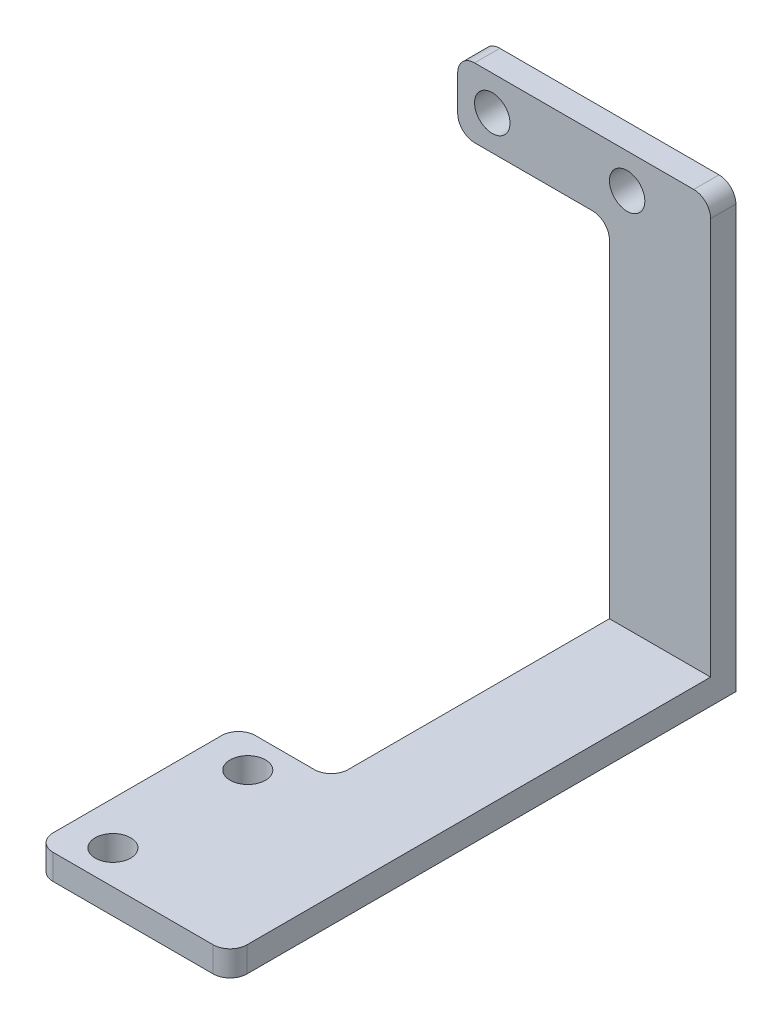
from build123d import *

# Parameters (mm, degrees)
SKETCH1_R           = 2.1
BOSS_EXTRUDE1_DEPTH = 3
SKETCH2_R           = 2.1
BOSS_EXTRUDE2_DEPTH = 3
FILLET1_R           = 2


with BuildPart() as part:
    # Sketch1 → Boss-Extrude1 (new body)
    with BuildSketch(Plane(origin=(0, 0, 0), x_dir=(1, 0, 0), z_dir=(0, 1, 0))):
        Polygon((-6, 0), (6, 0), (6, -57), (-17, -57), (-17, -33), (-6, -33), align=None)
        with Locations((-11.9, -37)):
            Circle(SKETCH1_R, mode=Mode.SUBTRACT)
        with Locations((-11.9, -53)):
            Circle(SKETCH1_R, mode=Mode.SUBTRACT)
    extrude(amount=BOSS_EXTRUDE1_DEPTH)

    # Sketch2 → Boss-Extrude2 (add)
    with BuildSketch(Plane.XY):
        Polygon((6, 0), (-6, 0), (-6, 43.9), (-24, 43.9), (-24, 52.1), (6, 52.1), align=None)
        with Locations((-19.9, 48)):
            Circle(SKETCH2_R, mode=Mode.SUBTRACT)
        with Locations((-3.9, 48)):
            Circle(SKETCH2_R, mode=Mode.SUBTRACT)
    extrude(amount=-BOSS_EXTRUDE2_DEPTH)

    # Fillet1
    fillet1_edges = [part.edges().sort_by_distance(p)[0] for p in [
        (6, 1.5, 57),
        (-17, 1.5, 57),
        (-17, 1.5, 33),
        (-6, 1.5, 33),
        (6, 52.1, -1.5),
        (-6, 43.9, -1.5),
        (-24, 43.9, -1.5),
        (-24, 52.1, -1.5),
    ]]
    fillet(fillet1_edges, radius=FILLET1_R)


solid = part.part
